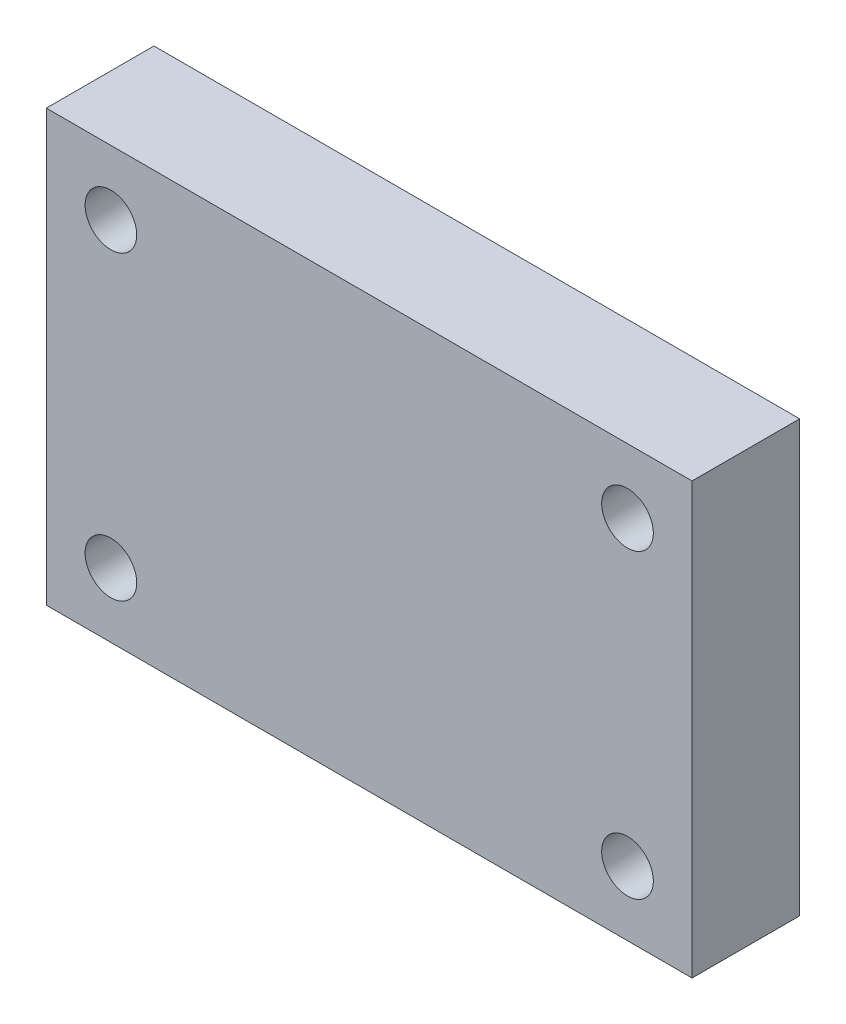
from build123d import *

# Parameters (mm, degrees)
SKETCH1_W           = 38.1
SKETCH1_H           = 25.4
SKETCH1_R           = 1.524
BOSS_EXTRUDE1_DEPTH = 6.35


with BuildPart() as part:
    # Sketch1 → Boss-Extrude1 (new body)
    with BuildSketch(Plane.XY):
        Rectangle(SKETCH1_W, SKETCH1_H)
        with Locations((-15.24, 8.89)):
            Circle(SKETCH1_R, mode=Mode.SUBTRACT)
        with Locations((-15.24, -8.89)):
            Circle(SKETCH1_R, mode=Mode.SUBTRACT)
        with Locations((15.24, 8.89)):
            Circle(SKETCH1_R, mode=Mode.SUBTRACT)
        with Locations((15.24, -8.89)):
            Circle(SKETCH1_R, mode=Mode.SUBTRACT)
    extrude(amount=BOSS_EXTRUDE1_DEPTH)


solid = part.part
